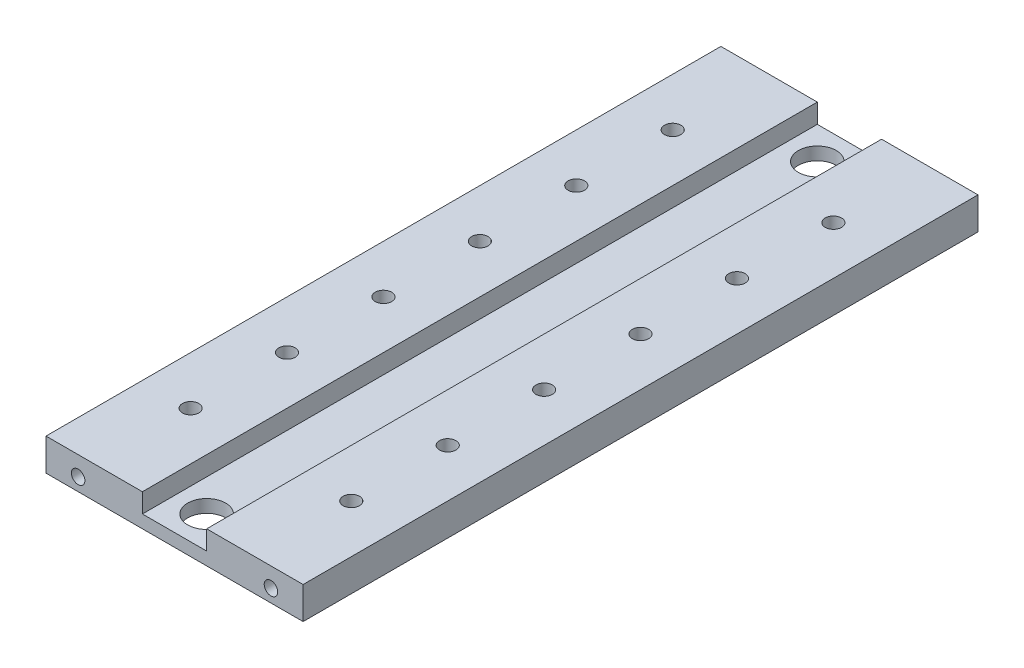
from build123d import *

# Parameters (mm, degrees)
AUFSATZ_LINEAR_AUSTRAGEN1_DEPTH = 105
M5_GEWINDEBOHRUNG1_D            = 4.2
M5_GEWINDEBOHRUNG1_DEPTH        = 14
M5_GEWINDEBOHRUNG1_TIP          = 1.2618073
M5_GEWINDEBOHRUNG2_D            = 4.2
M5_GEWINDEBOHRUNG2_DEPTH        = 14
M5_GEWINDEBOHRUNG2_TIP          = 1.2618073
SKIZZE10_R                      = 2.55
SCHNITT_LINEAR_AUSTRAGEN1_DEPTH = 11
G1_4_GEWINDEBOHRUNG1_D          = 11.8


with BuildPart() as part:
    # Skizze1 → Aufsatz-Linear austragen1 (new body, symmetric)
    with BuildSketch(Plane.XY):
        Polygon((-40, 0), (40, 0), (40, 10), (10, 10), (10, 4), (-10, 4), (-10, 10), (-40, 10), align=None)
    extrude(amount=AUFSATZ_LINEAR_AUSTRAGEN1_DEPTH, both=True)

    # M5 Gewindebohrung1
    with Locations(Plane.XY.offset(105)):
        with Locations((-30, 4), (30, 4)):
            Hole(M5_GEWINDEBOHRUNG1_D / 2, depth=M5_GEWINDEBOHRUNG1_DEPTH)
            with Locations((0, 0, -(M5_GEWINDEBOHRUNG1_DEPTH + M5_GEWINDEBOHRUNG1_TIP / 2))):  # 118° drill point
                Cone(0, M5_GEWINDEBOHRUNG1_D / 2, M5_GEWINDEBOHRUNG1_TIP, mode=Mode.SUBTRACT)

    # M5 Gewindebohrung2
    with Locations(Plane(origin=(0, 0, -105), x_dir=(-1, 0, 0), z_dir=(0, 0, -1))):
        with Locations((-25, 4), (25, 4)):
            Hole(M5_GEWINDEBOHRUNG2_D / 2, depth=M5_GEWINDEBOHRUNG2_DEPTH)
            with Locations((0, 0, -(M5_GEWINDEBOHRUNG2_DEPTH + M5_GEWINDEBOHRUNG2_TIP / 2))):  # 118° drill point
                Cone(0, M5_GEWINDEBOHRUNG2_D / 2, M5_GEWINDEBOHRUNG2_TIP, mode=Mode.SUBTRACT)

    # Skizze10 → Schnitt-Linear austragen1 (cut, through all)
    with BuildSketch(Plane(origin=(0, 10, 0), x_dir=(1, 0, 0), z_dir=(0, 1, 0))):
        with Locations((25, 75)):
            Circle(SKIZZE10_R)
        with Locations((25, 45)):
            Circle(SKIZZE10_R)
        with Locations((25, 15)):
            Circle(SKIZZE10_R)
        with Locations((25, -15)):
            Circle(SKIZZE10_R)
        with Locations((25, -45)):
            Circle(SKIZZE10_R)
        with Locations((25, -75)):
            Circle(SKIZZE10_R)
        with Locations((-25, -75)):
            Circle(SKIZZE10_R)
        with Locations((-25, -45)):
            Circle(SKIZZE10_R)
        with Locations((-25, -15)):
            Circle(SKIZZE10_R)
        with Locations((-25, 15)):
            Circle(SKIZZE10_R)
        with Locations((-25, 45)):
            Circle(SKIZZE10_R)
        with Locations((-25, 75)):
            Circle(SKIZZE10_R)
    extrude(amount=-SCHNITT_LINEAR_AUSTRAGEN1_DEPTH, mode=Mode.SUBTRACT)

    # G1/4 Gewindebohrung1 (through all)
    with Locations(Plane(origin=(0, 4, 0), x_dir=(1, 0, 0), z_dir=(0, 1, 0))):
        with Locations((0, 95), (0, -95)):
            Hole(G1_4_GEWINDEBOHRUNG1_D / 2)


solid = part.part
